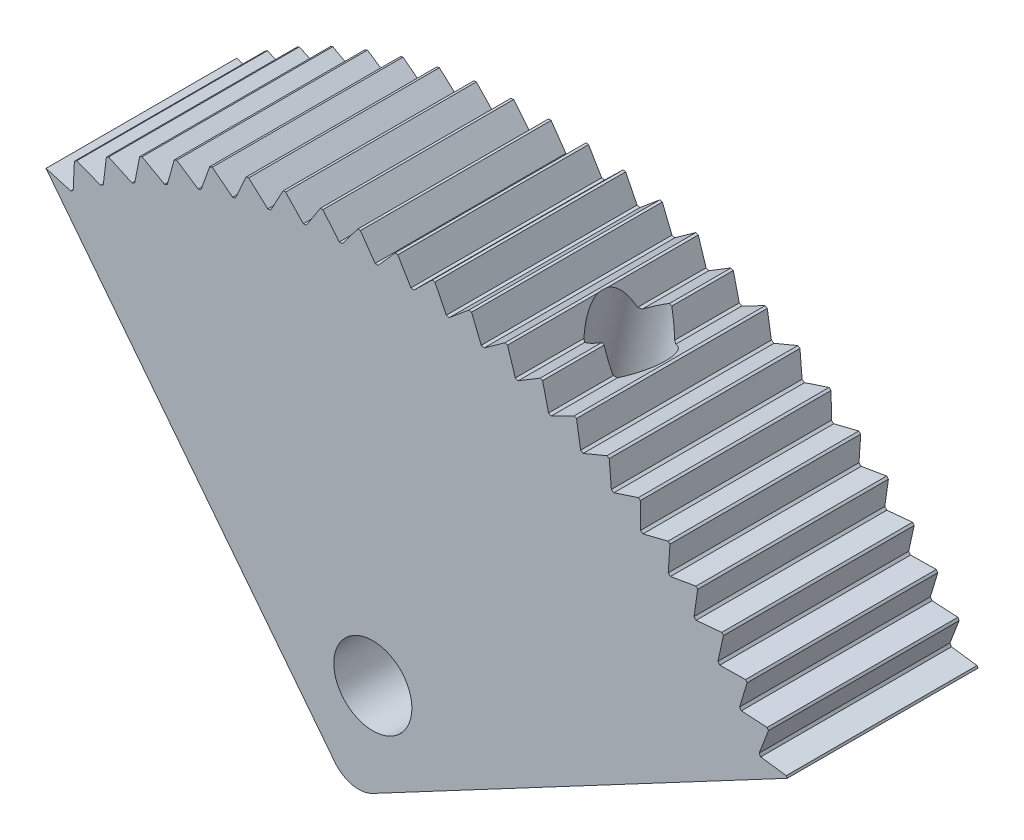
from build123d import *

# Parameters (mm, degrees)
BOSS_EXTRUDE1_DEPTH      = 3.175
BOSS_EXTRUDE1_DEPTH_BACK = 3.175
SKETCH1_R                = 1.3
SKETCH4_R                = 0.75
CUT_EXTRUDE2_DEPTH       = 7.5
CUT_EXTRUDE2_DEPTH_BACK  = 10
SKETCH3_R                = 1.1303
CUT_EXTRUDE3_DEPTH       = 10
CUT_EXTRUDE3_DEPTH_BACK  = 10


with BuildPart() as part:
    # Sketch1 → Boss-Extrude1 (new, two sides: drawn at the far end of the back side and taken through both)
    with BuildSketch(Plane.XY.offset(-BOSS_EXTRUDE1_DEPTH_BACK)):
        with BuildLine():
            Line((-19.351944596, 11.121666082), (-9.732209918, -1.193299023))
            ThreePointArc((-9.732209918, -1.193299023), (-9.152143222, -1.55583694), (-8.474751471, -1.460697412))
            Line((-8.474751471, -1.460697412), (5.323571039, 5.874420633))
            ThreePointArc((5.323571039, 5.874420633), (-5.801036197, 14.202963476), (-19.351944596, 11.121666082))
        make_face()
        with Locations((-8.471265065, 1.646037216)):
            Circle(SKETCH1_R, mode=Mode.SUBTRACT)
    extrude(amount=BOSS_EXTRUDE1_DEPTH + BOSS_EXTRUDE1_DEPTH_BACK)

    # Cut-Sweep1: sweep along a path in Sketch2
    with BuildLine(Plane.XY) as cut_sweep1_path:
        Line((-16.021378593, 6.857951387), (3.426511905, 2.722359798))
    # Sketch4 → Cut-Sweep1 (sweep, cut)
    with BuildSketch(Plane(origin=(-6.623066075, -5.173554115, 0), x_dir=(0, 0, 1), z_dir=(-0.7880657186592105, -0.6155911167927476, 0))):
        with Locations((0, 15.267134729)):
            Circle(SKETCH4_R)
    sweep(path=cut_sweep1_path.line, mode=Mode.SUBTRACT)

    # Sketch3 → Cut-Extrude2 (cut, two sides: drawn at the far end of the back side and taken through both)
    with BuildSketch(Plane(origin=(2.63861758, 12.40827211, 0), x_dir=(0.9781290338253494, -0.2079990220839719, 0), z_dir=(-0.2079990220839719, -0.9781290338253494, 0)).offset(-CUT_EXTRUDE2_DEPTH_BACK)):
        with Locations((-5.633213298, 0)):
            Circle(SKETCH3_R)
    extrude(amount=CUT_EXTRUDE2_DEPTH + CUT_EXTRUDE2_DEPTH_BACK, mode=Mode.SUBTRACT)

    # Sketch5 → Cut-Extrude3 (cut, two sides: drawn at the far end of the back side and taken through both)
    with BuildSketch(Plane.XY.offset(-CUT_EXTRUDE3_DEPTH_BACK)):
        with BuildLine():
            Line((-18.335959881, 11.845477975), (-17.532299102, 11.545639171))
            Line((-17.532299102, 11.545639171), (-17.446850408, 11.59758646))
            Line((-17.446850408, 11.59758646), (-17.343115269, 12.449063399))
            ThreePointArc((-17.343115269, 12.449063399), (-17.844834345, 12.155983405), (-18.335959881, 11.845477975))
        make_face()
        with BuildLine():
            Line((-19.351944596, 11.121666082), (-18.527988766, 10.883190202))
            Line((-18.527988766, 10.883190202), (-18.446694016, 10.941423901))
            Line((-18.446694016, 10.941423901), (-18.407365445, 11.798294498))
            ThreePointArc((-18.407365445, 11.798294498), (-18.88559278, 11.468269454), (-19.351944596, 11.121666082))
        make_face()
        with BuildLine():
            Line((-17.268359717, 12.490736443), (-16.489556709, 12.131237025))
            Line((-16.489556709, 12.131237025), (-16.400439201, 12.176602977))
            Line((-16.400439201, 12.176602977), (-16.23288644, 13.017852066))
            ThreePointArc((-16.23288644, 13.017852066), (-16.755248788, 12.763381061), (-17.268359717, 12.490736443))
        make_face()
        with BuildLine():
            Line((-16.15520532, 13.053778081), (-15.405681675, 12.636659079))
            Line((-15.405681675, 12.636659079), (-15.313401308, 12.675186133))
            Line((-15.313401308, 12.675186133), (-15.082982195, 13.501431247))
            ThreePointArc((-15.082982195, 13.501431247), (-15.623022142, 13.287013969), (-16.15520532, 13.053778081))
        make_face()
        with BuildLine():
            Line((-15.002816533, 13.531406266), (-14.286827611, 13.059035839))
            Line((-14.286827611, 13.059035839), (-14.191908301, 13.090505261))
            Line((-14.191908301, 13.090505261), (-13.89993102, 13.89705546))
            ThreePointArc((-13.89993102, 13.89705546), (-14.454582535, 13.723909246), (-15.002816533, 13.531406266))
        make_face()
        with BuildLine():
            Line((-13.817735952, 13.920909302), (-13.139346723, 13.395969296))
            Line((-13.139346723, 13.395969296), (-13.042327365, 13.42020242))
            Line((-13.042327365, 13.42020242), (-12.690449596, 14.202478581))
            ThreePointArc((-12.690449596, 14.202478581), (-13.256563688, 14.071586455), (-13.817735952, 13.920909302))
        make_face()
        with BuildLine():
            Line((-12.606691776, 14.220075817), (-11.96975374, 13.645546536))
            Line((-11.96975374, 13.645546536), (-11.871185156, 13.662405782))
            Line((-11.871185156, 13.662405782), (-11.461404655, 14.415966594))
            ThreePointArc((-11.461404655, 14.415966594), (-12.035767257, 14.328071685), (-12.606691776, 14.220075817))
        make_face()
        with BuildLine():
            Line((-11.376559612, 14.427207318), (-10.784688934, 13.806350606))
            Line((-10.784688934, 13.806350606), (-10.685130738, 13.815740255))
            Line((-10.685130738, 13.815740255), (-10.219774001, 14.536307437))
            ThreePointArc((-10.219774001, 14.536307437), (-10.799124216, 14.491908762), (-11.376559612, 14.427207318))
        make_face()
        with BuildLine():
            Line((-10.134323437, 14.541127831), (-9.590880415, 13.877468553))
            Line((-9.590880415, 13.877468553), (-9.49089784, 13.879335297))
            Line((-9.49089784, 13.879335297), (-8.972606893, 14.562817887))
            ThreePointArc((-8.972606893, 14.562817887), (-9.553655506, 14.562167515), (-10.134323437, 14.541127831))
        make_face()
        with BuildLine():
            Line((-8.887035946, 14.561190583), (-8.395105934, 13.85849661))
            Line((-8.395105934, 13.85849661), (-8.295266624, 13.852829851))
            Line((-8.295266624, 13.852829851), (-7.726984022, 14.49534743))
            ThreePointArc((-7.726984022, 14.49534743), (-8.306432177, 14.538449054), (-8.887035946, 14.561190583))
        make_face()
        with BuildLine():
            Line((-7.641778514, 14.487281668), (-7.204154406, 13.749542489))
            Line((-7.204154406, 13.749542489), (-7.10502519, 13.736374399))
            Line((-7.10502519, 13.736374399), (-6.489977312, 14.334279127))
            ThreePointArc((-6.489977312, 14.334279127), (-7.064535238, 14.420888041), (-7.641778514, 14.487281668))
        make_face()
        with BuildLine():
            Line((-6.405620991, 14.319820698), (-6.024787362, 13.551224769))
            Line((-6.024787362, 13.551224769), (-5.926931038, 13.530630109))
            Line((-5.926931038, 13.530630109), (-5.268609769, 14.080527429))
            ThreePointArc((-5.268609769, 14.080527429), (-5.835015459, 14.210151917), (-6.405620991, 14.319820698))
        make_face()
        with BuildLine():
            Line((-5.185581561, 14.05975842), (-4.863700563, 13.264669382))
            Line((-4.863700563, 13.264669382), (-4.767672704, 13.236765076))
            Line((-4.767672704, 13.236765076), (-4.06981561, 13.73553299))
            ThreePointArc((-4.06981561, 13.73553299), (-4.624853342, 13.907437121), (-5.185581561, 14.05975842))
        make_face()
        with BuildLine():
            Line((-3.9885869, 13.708571317), (-3.727485988, 12.891503223))
            Line((-3.727485988, 12.891503223), (-3.633831783, 12.856447697))
            Line((-3.633831783, 12.856447697), (-2.900400891, 13.30125449))
            ThreePointArc((-2.900400891, 13.30125449), (-3.440919483, 13.514462291), (-3.9885869, 13.708571317))
        make_face()
        with BuildLine():
            Line((-2.82143285, 13.268253224), (-2.622594402, 12.433844914))
            Line((-2.622594402, 12.433844914), (-2.531845566, 12.391837192))
            Line((-2.531845566, 12.391837192), (-1.767004872, 12.78015751))
            ThreePointArc((-1.767004872, 12.78015751), (-2.289935572, 13.033458511), (-2.82143285, 13.268253224))
        make_face()
        with BuildLine():
            Line((-1.690745835, 12.741304013), (-1.55529874, 11.894292773))
            Line((-1.55529874, 11.894292773), (-1.467970492, 11.84557135))
            Line((-1.467970492, 11.84557135), (-0.676062318, 12.175200535))
            ThreePointArc((-0.676062318, 12.175200535), (-1.178436229, 12.46715664), (-1.690745835, 12.741304013))
        make_face()
        with BuildLine():
            Line((-0.602945237, 12.130715396), (-0.531658487, 11.275910064))
            Line((-0.531658487, 11.275910064), (-0.448246626, 11.220751552))
            Line((-0.448246626, 11.220751552), (0.366233034, 11.489818161))
            ThreePointArc((0.366233034, 11.489818161), (-0.112731901, 11.818771812), (-0.602945237, 12.130715396))
        make_face()
        with BuildLine():
            Line((0.43579304, 11.439953939), (0.442514722, 10.582207604))
            Line((0.442514722, 10.582207604), (0.521536632, 10.520925162))
            Line((0.521536632, 10.520925162), (1.353963634, 10.72790159))
            ThreePointArc((1.353963634, 10.72790159), (0.90112696, 11.091985181), (0.43579304, 11.439953939))
        make_face()
        with BuildLine():
            Line((1.419571645, 10.672941387), (1.361690097, 9.817123835))
            Line((1.361690097, 9.817123835), (1.435873415, 9.750065388))
            Line((1.435873415, 9.750065388), (2.281521722, 9.893776544))
            ThreePointArc((2.281521722, 9.893776544), (1.857384253, 10.290923018), (1.419571645, 10.672941387))
        make_face()
        with BuildLine():
            Line((2.342805254, 9.834032391), (2.220649092, 8.985002457))
            Line((2.220649092, 8.985002457), (2.289572649, 8.912548725))
            Line((2.289572649, 8.912548725), (3.143641161, 8.9921787))
            ThreePointArc((3.143641161, 8.9921787), (2.750610903, 9.42013329), (2.342805254, 9.834032391))
        make_face()
        with BuildLine():
            Line((3.200252281, 8.92798979), (3.014515038, 8.090567774))
            Line((3.014515038, 8.090567774), (3.077787526, 8.013130106))
            Line((3.077787526, 8.013130106), (3.935427337, 8.028226808))
            ThreePointArc((3.935427337, 8.028226808), (3.575735688, 8.484559836), (3.200252281, 8.92798979))
        make_face()
        with BuildLine():
            Line((3.98704464, 7.959957568), (3.738780825, 7.138897866))
            Line((3.738780825, 7.138897866), (3.796043018, 7.056915909))
            Line((3.796043018, 7.056915909), (4.652384947, 7.007393627))
            ThreePointArc((4.652384947, 7.007393627), (4.328074028, 7.489514298), (3.98704464, 7.959957568))
        make_face()
        with BuildLine():
            Line((4.69871538, 6.93543165), (4.38933449, 6.135395762))
            Line((4.38933449, 6.135395762), (4.440261288, 6.049334963))
            Line((4.440261288, 6.049334963), (5.290443523, 5.935474855))
            ThreePointArc((5.290443523, 5.935474855), (5.003354583, 6.440645969), (4.69871538, 6.93543165))
        make_face()
    extrude(amount=CUT_EXTRUDE3_DEPTH + CUT_EXTRUDE3_DEPTH_BACK, mode=Mode.SUBTRACT)


solid = part.part
